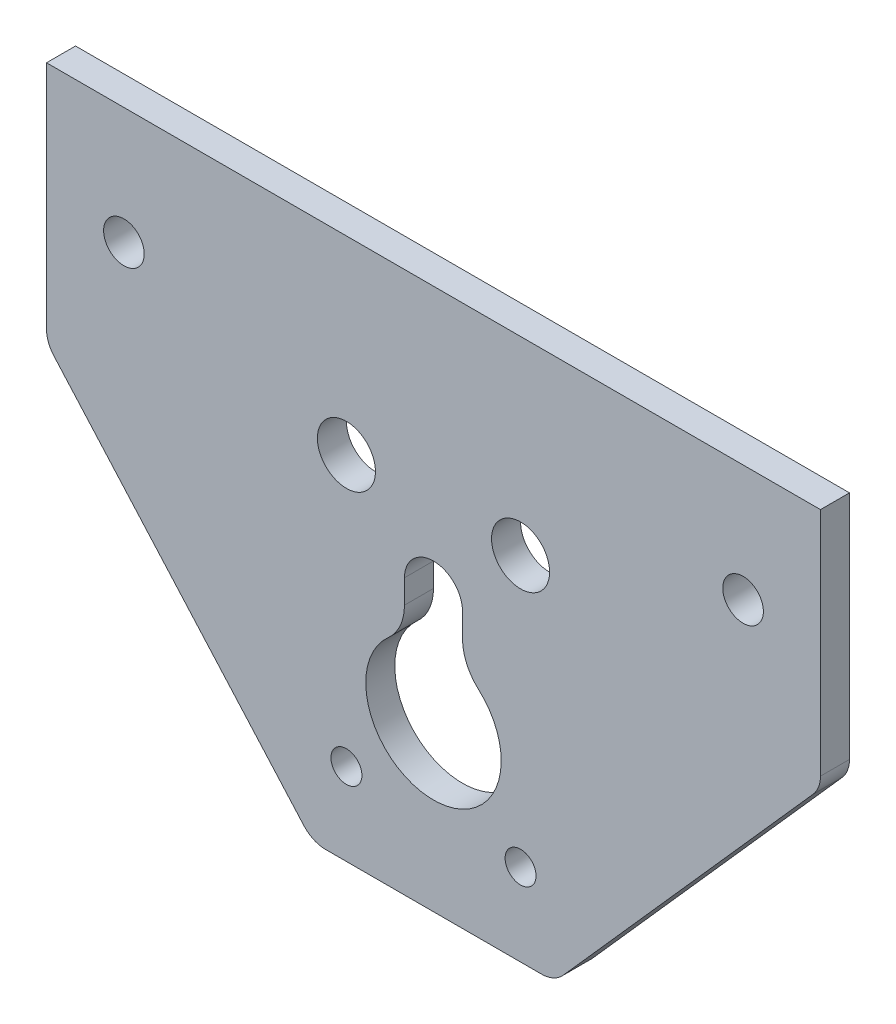
from build123d import *

# Parameters (mm, degrees)
SKETCH2_R           = 7
SKETCH2_R_2         = 1.6
BOSS_EXTRUDE1_DEPTH = 3
SKETCH3_R           = 2.1
CUT_EXTRUDE1_DEPTH  = 10
FILLET1_R           = 3
SKETCH4_R           = 3
CUT_EXTRUDE2_DEPTH  = 10
FILLET2_R           = 5


with BuildPart() as part:
    # Sketch2 → Boss-Extrude1 (new body)
    with BuildSketch(Plane.XY):
        Polygon((-12.5, -17), (12.5, -17), (40, 14), (40, 39), (-40, 39), (-40, 14), align=None)
        Circle(SKETCH2_R, mode=Mode.SUBTRACT)
        with Locations((-9, -8.5)):
            Circle(SKETCH2_R_2, mode=Mode.SUBTRACT)
        with Locations((9, -8.5)):
            Circle(SKETCH2_R_2, mode=Mode.SUBTRACT)
    extrude(amount=BOSS_EXTRUDE1_DEPTH)

    # Sketch3 → Cut-Extrude1 (cut)
    with BuildSketch(Plane.XY.offset(3)):
        with Locations((31.999, 26.93)):
            Circle(SKETCH3_R)
        with Locations((-31.999, 26.93)):
            Circle(SKETCH3_R)
    extrude(amount=-CUT_EXTRUDE1_DEPTH, mode=Mode.SUBTRACT)

    # Fillet1
    fillet1_edges = [part.edges().sort_by_distance(p)[0] for p in [
        (-40, 14, 1.5),
        (40, 14, 1.5),
        (12.5, -17, 1.5),
        (-12.5, -17, 1.5),
    ]]
    fillet(fillet1_edges, radius=FILLET1_R)

    # Sketch4 → Cut-Extrude2 (cut)
    with BuildSketch(Plane.XY.offset(3)):
        with Locations((9, 19.4)):
            Circle(SKETCH4_R)
        with Locations((-9, 19.4)):
            Circle(SKETCH4_R)
        with BuildLine():
            Line((-3, 11.4), (-3, 6.32455532))
            ThreePointArc((-3, 6.32455532), (0, 7), (3, 6.32455532))
            Line((3, 6.32455532), (3, 11.4))
            ThreePointArc((3, 11.4), (0, 14.4), (-3, 11.4))
        make_face()
    extrude(amount=-CUT_EXTRUDE2_DEPTH, mode=Mode.SUBTRACT)

    # Fillet2
    fillet2_edges = [part.edges().sort_by_distance(p)[0] for p in [
        (-3, 6.32455532, 1.5),
        (3, 6.32455532, 1.5),
    ]]
    fillet(fillet2_edges, radius=FILLET2_R)


solid = part.part
